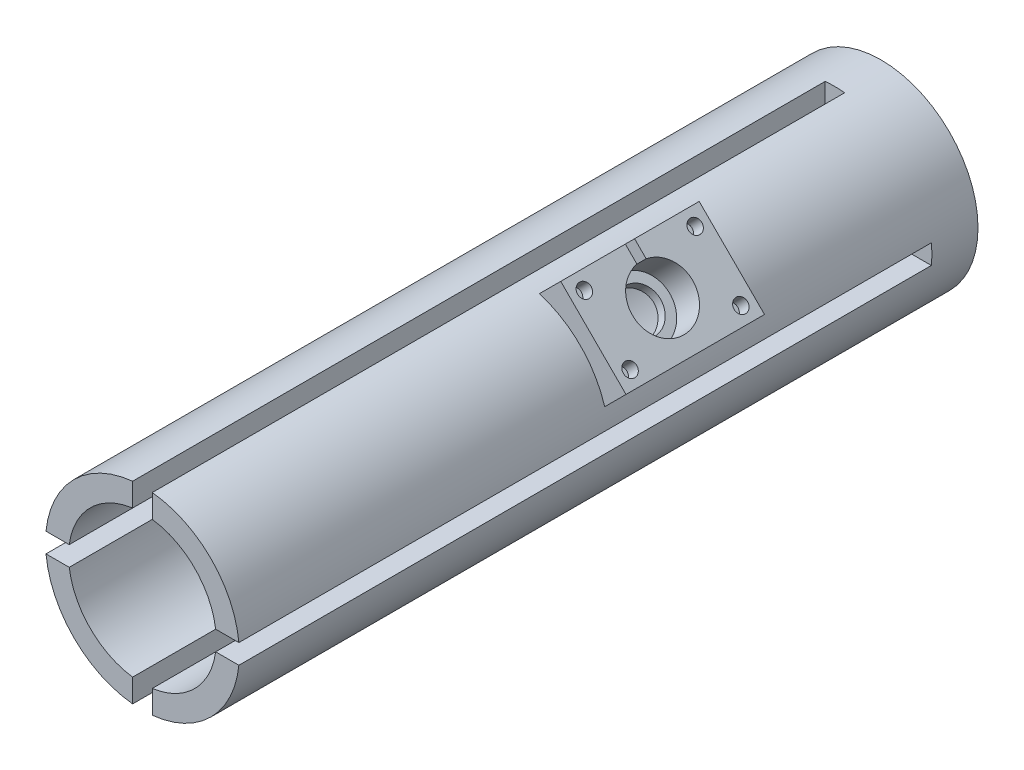
from build123d import *

# Parameters (mm, degrees)
BOSS_EXTRUDE2_DEPTH   = 203.2
BOSS_EXTRUDE2_2_DEPTH = 203.2
BOSS_EXTRUDE2_3_DEPTH = 203.2
BOSS_EXTRUDE2_4_DEPTH = 203.2
SKETCH1_15_R          = 26.67
SKETCH1_15_R_2        = 10.16
BOSS_EXTRUDE3_DEPTH   = 12.7
BOSS_EXTRUDE4_DEPTH   = 101.6
CUT_EXTRUDE2_DEPTH    = 63.5
SKETCH4_R             = 8.300000037
CUT_EXTRUDE3_DEPTH    = 8.89
SKETCH5_R             = 5.715
CUT_EXTRUDE5_DEPTH    = 25.4
SKETCH7_W             = 2.54
SKETCH7_H             = 6
CUT_EXTRUDE6_DEPTH    = 8.89
SKETCH8_R             = 1.8542
CUT_EXTRUDE7_DEPTH    = 3.81


with BuildPart() as part:
    # Sketch1 → Boss-Extrude2 (new body)
    with BuildSketch(Plane.XY):
        with BuildLine():
            Line((-26.533104764, 2.69875), (-20.139988789, 2.69875))
            ThreePointArc((-20.139988789, 2.69875), (-14.368409794, 14.368409794), (-2.69875, 20.139988789))
            Line((-2.69875, 20.139988789), (-2.69875, 26.533104764))
            ThreePointArc((-2.69875, 26.533104764), (-18.858537854, 18.858537854), (-26.533104764, 2.69875))
        make_face()
    extrude(amount=BOSS_EXTRUDE2_DEPTH)



with BuildPart() as body_2:
    # Sketch1 → Boss-Extrude2 2 (new body)
    with BuildSketch(Plane.XY):
        with BuildLine():
            ThreePointArc((-2.69875, -20.139988789), (-14.368409794, -14.368409794), (-20.139988789, -2.69875))
            Line((-20.139988789, -2.69875), (-26.533104764, -2.69875))
            ThreePointArc((-26.533104764, -2.69875), (-18.858537854, -18.858537854), (-2.69875, -26.533104764))
            Line((-2.69875, -26.533104764), (-2.69875, -20.139988789))
        make_face()
    extrude(amount=BOSS_EXTRUDE2_2_DEPTH)


with BuildPart() as body_3:
    # Sketch1 → Boss-Extrude2 3 (new body)
    with BuildSketch(Plane.XY):
        with BuildLine():
            Line((2.69875, 26.533104764), (2.69875, 20.139988789))
            ThreePointArc((2.69875, 20.139988789), (14.368409794, 14.368409794), (20.139988789, 2.69875))
            Line((20.139988789, 2.69875), (26.533104764, 2.69875))
            ThreePointArc((26.533104764, 2.69875), (18.858537854, 18.858537854), (2.69875, 26.533104764))
        make_face()
    extrude(amount=BOSS_EXTRUDE2_3_DEPTH)


with BuildPart() as body_4:
    # Sketch1 → Boss-Extrude2 4 (new body)
    with BuildSketch(Plane.XY):
        with BuildLine():
            ThreePointArc((20.139988789, -2.69875), (14.368409794, -14.368409794), (2.69875, -20.139988789))
            Line((2.69875, -20.139988789), (2.69875, -26.533104764))
            ThreePointArc((2.69875, -26.533104764), (18.858537854, -18.858537854), (26.533104764, -2.69875))
            Line((26.533104764, -2.69875), (20.139988789, -2.69875))
        make_face()
    extrude(amount=BOSS_EXTRUDE2_4_DEPTH)


with BuildPart() as part_1:
    add(part.part)

    add(body_2.part)  # Boss-Extrude3 merges body 2

    add(body_3.part)  # Boss-Extrude3 merges body 3

    add(body_4.part)  # Boss-Extrude3 merges body 4
    # Sketch1_15 → Boss-Extrude3 (add)
    with BuildSketch(Plane.XY):
        Circle(SKETCH1_15_R)
        Circle(SKETCH1_15_R_2, mode=Mode.SUBTRACT)
    extrude(amount=BOSS_EXTRUDE3_DEPTH)

    # Sketch1_18 → Boss-Extrude4 (add)
    with BuildSketch(Plane.XY):
        with BuildLine():
            Line((13.470384182, 31.430896424), (7.602851248, 25.56336349))
            ThreePointArc((7.602851248, 25.56336349), (18.858537854, 18.858537854), (25.56336349, 7.602851248))
            Line((25.56336349, 7.602851248), (31.430896424, 13.470384182))
            Line((31.430896424, 13.470384182), (13.470384182, 31.430896424))
        make_face()
    extrude(amount=BOSS_EXTRUDE4_DEPTH)

    # Sketch1_19 → Cut-Extrude2 (cut)
    with BuildSketch(Plane.XY):
        with BuildLine():
            Line((13.470384182, 31.430896424), (7.602851248, 25.56336349))
            ThreePointArc((7.602851248, 25.56336349), (18.858537854, 18.858537854), (25.56336349, 7.602851248))
            Line((25.56336349, 7.602851248), (31.430896424, 13.470384182))
            Line((31.430896424, 13.470384182), (13.470384182, 31.430896424))
        make_face()
    extrude(amount=CUT_EXTRUDE2_DEPTH, mode=Mode.SUBTRACT)

    # Sketch4 → Cut-Extrude3 (cut)
    with BuildSketch(Plane(origin=(22.450640303, 22.450640303, 0), x_dir=(0, 0, -1), z_dir=(0.7071067811865466, 0.7071067811865485, 0))):
        with Locations((-82.55, 0)):
            Circle(SKETCH4_R)
    extrude(amount=-CUT_EXTRUDE3_DEPTH, mode=Mode.SUBTRACT)

    # Sketch5 → Cut-Extrude5 (cut)
    with BuildSketch(Plane(origin=(22.450640303, 22.450640303, 0), x_dir=(0, 0, -1), z_dir=(0.7071067811865466, 0.7071067811865485, 0))):
        with Locations((-82.55, 0)):
            Circle(SKETCH5_R)
    extrude(amount=-CUT_EXTRUDE5_DEPTH, mode=Mode.SUBTRACT)

    # Sketch7 → Cut-Extrude6 (cut)
    with BuildSketch(Plane(origin=(-8.980256121, 8.980256121, 0), x_dir=(0, 0, 1), z_dir=(-0.7071067811865488, 0.7071067811865462, 0))):
        with Locations((82.55, 28.75)):
            Rectangle(SKETCH7_W, SKETCH7_H)
    extrude(amount=-CUT_EXTRUDE6_DEPTH, mode=Mode.SUBTRACT)

    # Sketch8 → Cut-Extrude7 (cut)
    with BuildSketch(Plane(origin=(22.450640303, 22.450640303, 0), x_dir=(0, 0, -1), z_dir=(0.7071067811865466, 0.7071067811865485, 0))):
        with Locations((-97.79, 8.89)):
            Circle(SKETCH8_R)
        with Locations((-97.79, -8.89)):
            Circle(SKETCH8_R)
        with Locations((-67.31, -8.89)):
            Circle(SKETCH8_R)
        with Locations((-67.31, 8.89)):
            Circle(SKETCH8_R)
    extrude(amount=-CUT_EXTRUDE7_DEPTH, mode=Mode.SUBTRACT)


solid = part_1.part
